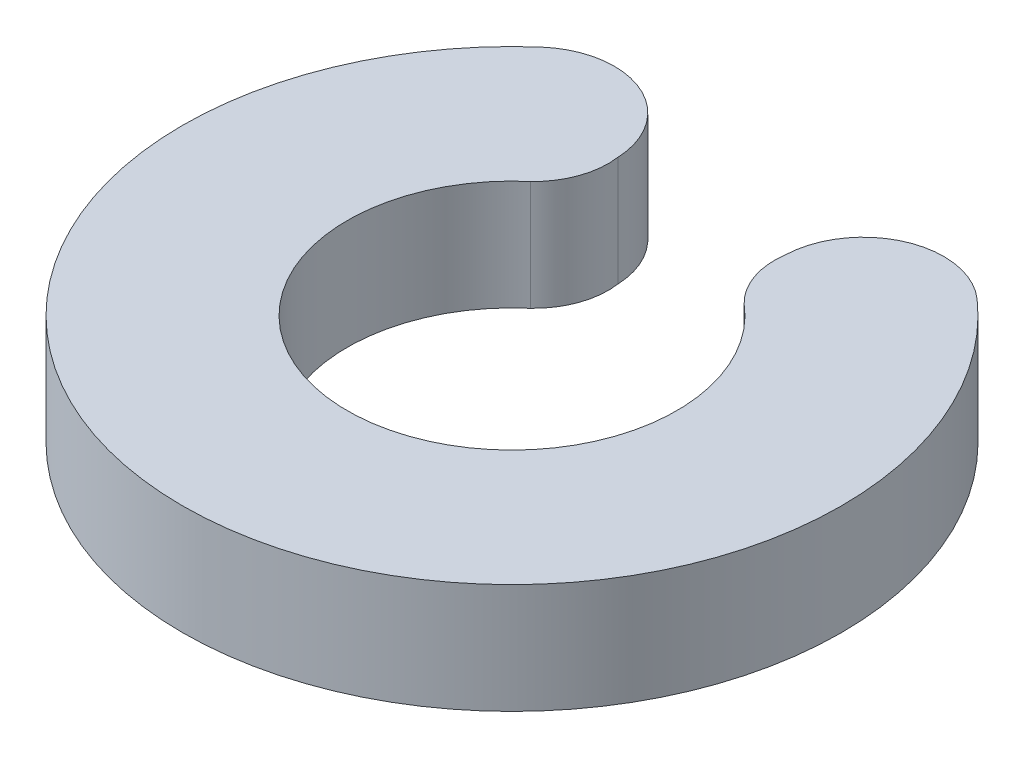
from build123d import *

# Parameters (mm, degrees)
BOSS_EXTRUDE1_DEPTH = 2


with BuildPart() as part:
    # Sketch1 → Boss-Extrude1 (new body)
    with BuildSketch(Plane(origin=(0, 0, 0), x_dir=(1, 0, 0), z_dir=(0, 1, 0))):
        with BuildLine():
            ThreePointArc((3, 0), (0, -3), (-3, 0))
            ThreePointArc((-3, 0), (-2.743755194, 1.213180711), (-2.018795042, 2.219113918))
            ThreePointArc((-2.018795042, 2.219113918), (-1.982332969, 2.251745101), (-1.945343535, 2.283777251))
            ThreePointArc((-1.945343535, 2.283777251), (-1.596748035, 2.82076449), (-1.5319755, 3.457693556))
            ThreePointArc((-1.5319755, 3.457693556), (-2.424767696, 4.747181988), (-3.972947107, 4.496186305))
            ThreePointArc((-3.972947107, 4.496186305), (0, -6), (3.972947107, 4.496186305))
            ThreePointArc((3.972947107, 4.496186305), (2.424767696, 4.747181988), (1.5319755, 3.457693556))
            ThreePointArc((1.5319755, 3.457693556), (1.590995928, 2.827214748), (1.932969653, 2.294259864))
            ThreePointArc((1.932969653, 2.294259864), (1.976239555, 2.257094863), (2.018795042, 2.219113918))
            ThreePointArc((2.018795042, 2.219113918), (2.743755194, 1.213180711), (3, 0))
        make_face()
    extrude(amount=BOSS_EXTRUDE1_DEPTH)


solid = part.part
